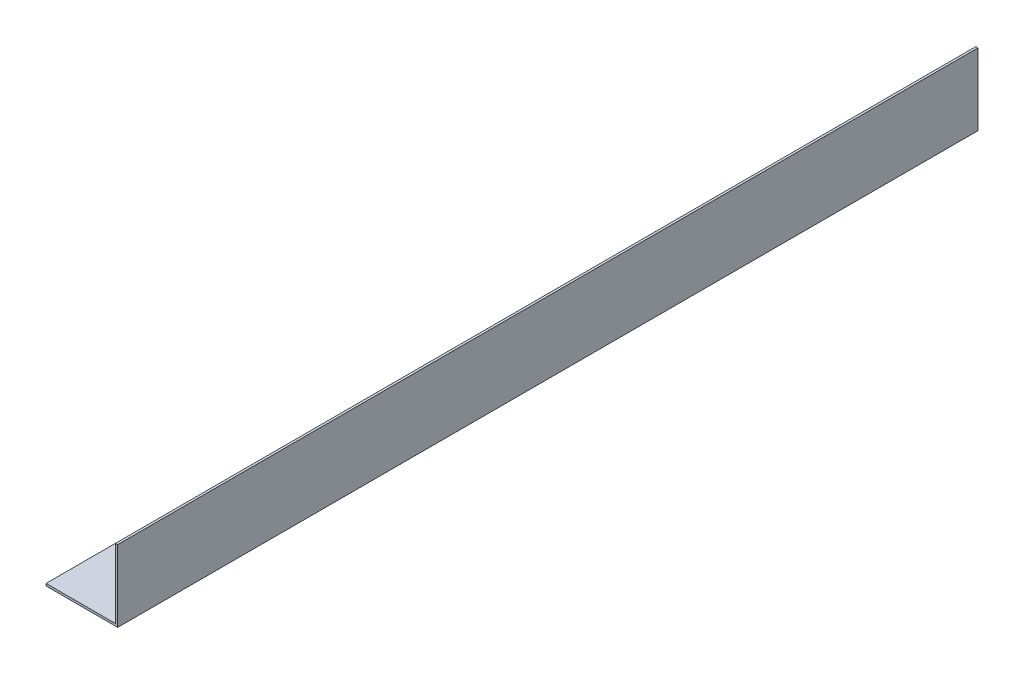
from build123d import *

# Parameters (mm, degrees)
EXTRUDE1_DEPTH     = 609.6
CUT_EXTRUDE1_DEPTH = 51.8


with BuildPart() as part:
    # Sketch1 → Extrude1 (new body)
    with BuildSketch(Plane.XY):
        Polygon((0, 0), (50.8, 0), (50.8, 50.8), (49.2125, 50.8), (49.2125, 1.5875), (0, 1.5875), align=None)
    extrude(amount=EXTRUDE1_DEPTH)

    # Sketch2 → Cut-Extrude1 (cut, through all)
    with BuildSketch(Plane.XZ):
        with BuildLine():
            Line((20.6375, 556.5521), (36.707174868, 556.5521))
            ThreePointArc((36.707174868, 556.5521), (40.809274868, 552.45), (36.707174868, 548.3479))
            Line((36.707174868, 548.3479), (20.6375, 548.3479))
            ThreePointArc((20.6375, 548.3479), (16.5354, 552.45), (20.6375, 556.5521))
        make_face()
        with BuildLine():
            Line((36.707174868, 61.2521), (20.6375, 61.2521))
            ThreePointArc((20.6375, 61.2521), (16.5354, 57.15), (20.6375, 53.0479))
            Line((20.6375, 53.0479), (36.707174868, 53.0479))
            ThreePointArc((36.707174868, 53.0479), (40.809274868, 57.15), (36.707174868, 61.2521))
        make_face()
    extrude(amount=-CUT_EXTRUDE1_DEPTH, mode=Mode.SUBTRACT)


solid = part.part
